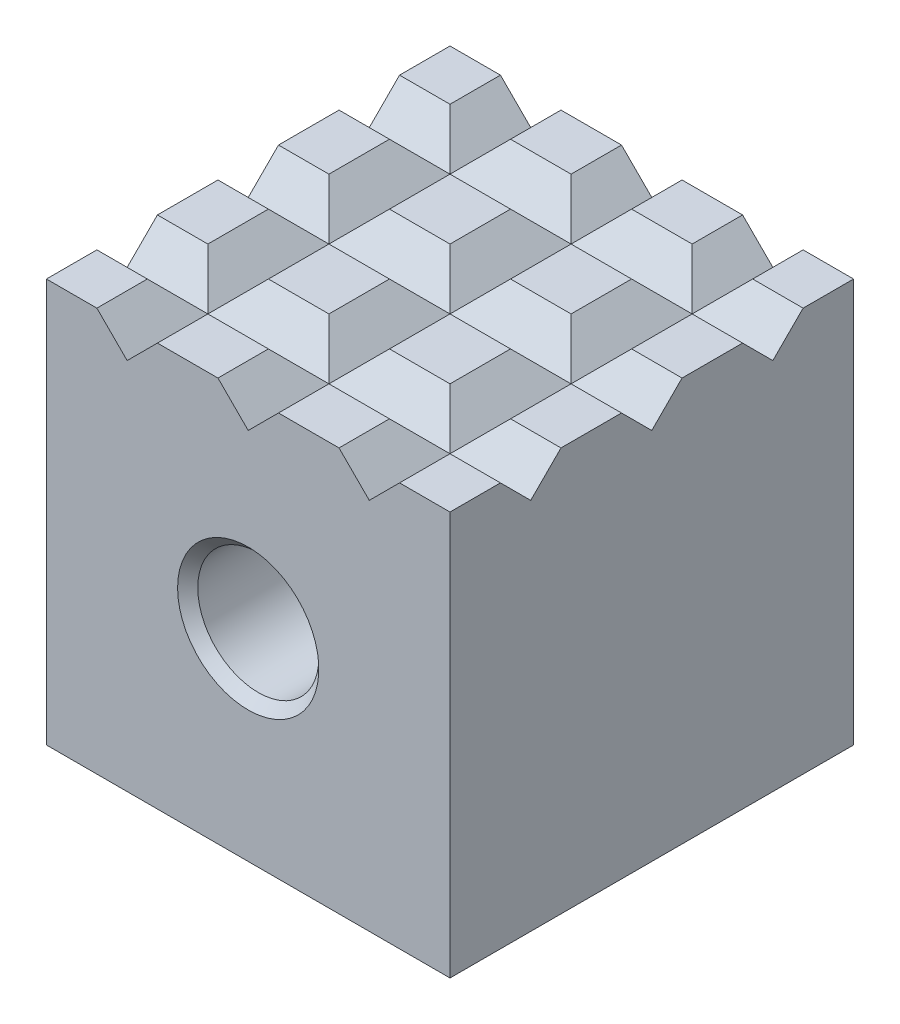
from build123d import *

# Parameters (mm, degrees)
SKETCH1_W               = 20
SKETCH1_H               = 20
BOSS_EXTRUDE1_DEPTH     = 20
SKETCH2_R               = 3
CUT_EXTRUDE1_DEPTH      = 21
CHAMFER1_SIZE           = 0.5
CUT_EXTRUDE2_DEPTH      = 11
CUT_EXTRUDE2_DEPTH_BACK = 11
CUT_EXTRUDE3_DEPTH      = 11
CUT_EXTRUDE3_DEPTH_BACK = 11


with BuildPart() as part:
    # Sketch1 → Boss-Extrude1 (new body)
    with BuildSketch(Plane(origin=(0, 0, 0), x_dir=(1, 0, 0), z_dir=(0, 1, 0))):
        Rectangle(SKETCH1_W, SKETCH1_H)
    extrude(amount=BOSS_EXTRUDE1_DEPTH)

    # Sketch2 → Cut-Extrude1 (cut, through all)
    with BuildSketch(Plane.XY.offset(10)):
        with Locations((0, 10)):
            Circle(SKETCH2_R)
    extrude(amount=-CUT_EXTRUDE1_DEPTH, mode=Mode.SUBTRACT)

    # Chamfer1
    chamfer1_edges = [part.edges().sort_by_distance(p)[0] for p in [
        (-3, 10, -10),
        (-3, 10, 10),
    ]]
    chamfer(chamfer1_edges, length=CHAMFER1_SIZE)

    # Sketch3 → Cut-Extrude2 (cut, two sides)
    with BuildSketch(Plane.XY) as cut_extrude2_sk:
        Polygon((-3.5, 21), (-6, 18.5), (-8.5, 21), align=None)
        Polygon((2.5, 21), (0, 18.5), (-2.5, 21), align=None)
        Polygon((8.5, 21), (6, 18.5), (3.5, 21), align=None)
    extrude(amount=CUT_EXTRUDE2_DEPTH, mode=Mode.SUBTRACT)
    extrude(cut_extrude2_sk.sketch, amount=-CUT_EXTRUDE2_DEPTH_BACK, mode=Mode.SUBTRACT)

    # Sketch4 → Cut-Extrude3 (cut, two sides)
    with BuildSketch(Plane(origin=(0, 0, 0), x_dir=(0, 0, -1), z_dir=(1, 0, 0))) as cut_extrude3_sk:
        Polygon((-3.5, 21), (-6, 18.5), (-8.5, 21), align=None)
        Polygon((2.5, 21), (0, 18.5), (-2.5, 21), align=None)
        Polygon((8.5, 21), (6, 18.5), (3.5, 21), align=None)
    extrude(amount=CUT_EXTRUDE3_DEPTH, mode=Mode.SUBTRACT)
    extrude(cut_extrude3_sk.sketch, amount=-CUT_EXTRUDE3_DEPTH_BACK, mode=Mode.SUBTRACT)


solid = part.part
